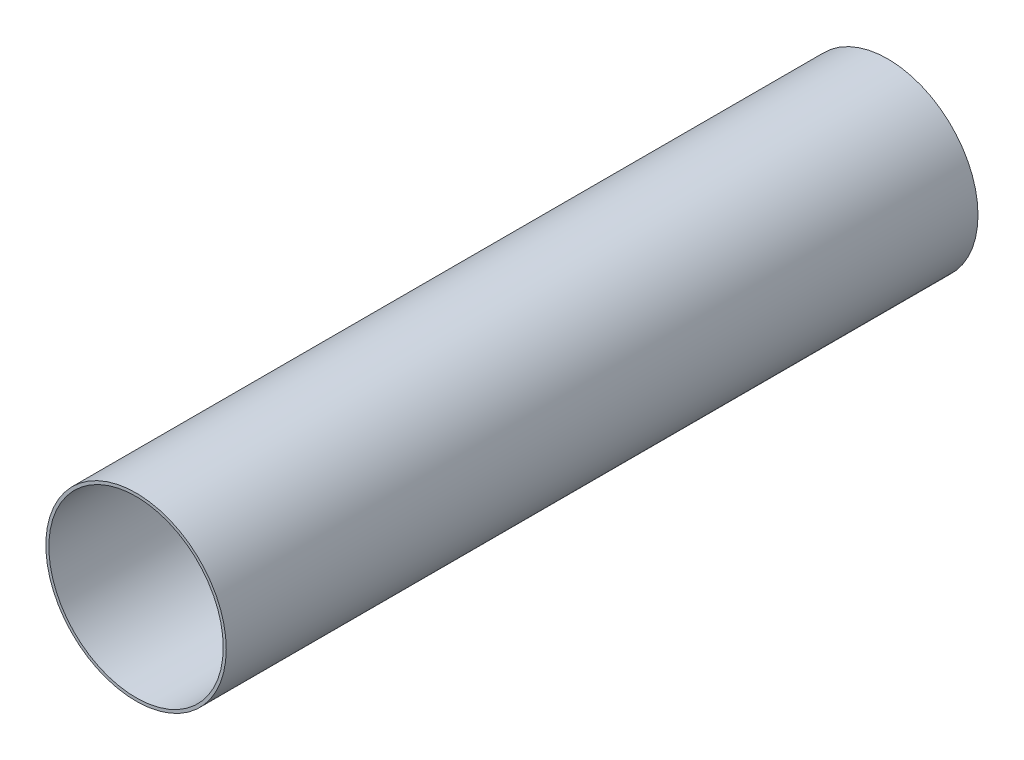
from build123d import *

# Parameters (mm, degrees)
ESQUISSE1_R        = 30
ESQUISSE1_R_2      = 29
BOSS_EXTRU_1_DEPTH = 250


with BuildPart() as part:
    # Esquisse1 → Boss.-Extru.1 (new body)
    with BuildSketch(Plane.XY):
        Circle(ESQUISSE1_R)
        Circle(ESQUISSE1_R_2, mode=Mode.SUBTRACT)
    extrude(amount=BOSS_EXTRU_1_DEPTH)


solid = part.part
